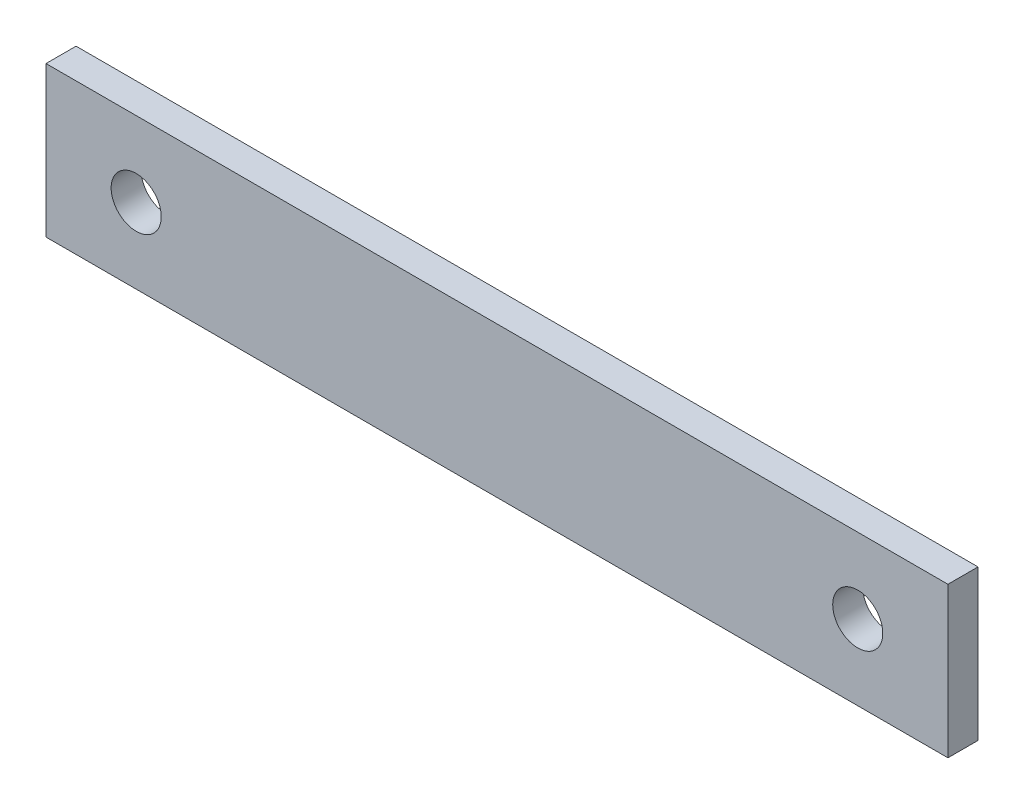
from build123d import *

# Parameters (mm, degrees)
SKETCH1_W           = 90
SKETCH1_H           = 15
SKETCH1_R           = 2.5
BOSS_EXTRUDE1_DEPTH = 3


with BuildPart() as part:
    # Sketch1 → Boss-Extrude1 (new body)
    with BuildSketch(Plane.XY):
        with Locations((45, 7.5)):
            Rectangle(SKETCH1_W, SKETCH1_H)
        with Locations((9, 7.5)):
            Circle(SKETCH1_R, mode=Mode.SUBTRACT)
        with Locations((81, 7.5)):
            Circle(SKETCH1_R, mode=Mode.SUBTRACT)
    extrude(amount=BOSS_EXTRUDE1_DEPTH)


solid = part.part
